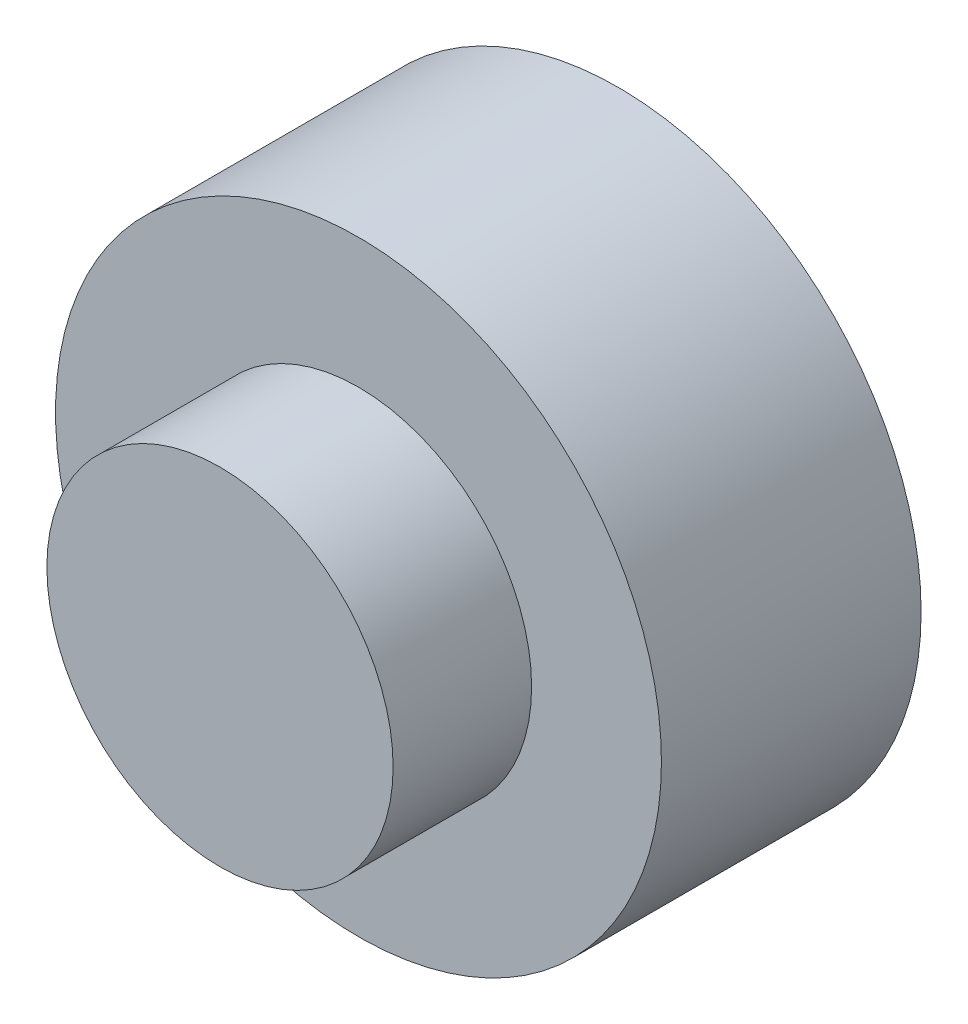
from build123d import *

# Parameters (mm, degrees)
SKETCH1_R           = 17.5
BOSS_EXTRUDE1_DEPTH = 15
SKETCH2_R           = 10
BOSS_EXTRUDE2_DEPTH = 8


with BuildPart() as part:
    # Sketch1 → Boss-Extrude1 (new body)
    with BuildSketch(Plane.XY):
        Circle(SKETCH1_R)
    extrude(amount=BOSS_EXTRUDE1_DEPTH)

    # Sketch2 → Boss-Extrude2 (add)
    with BuildSketch(Plane.XY.offset(15)):
        Circle(SKETCH2_R)
    extrude(amount=BOSS_EXTRUDE2_DEPTH)


solid = part.part
